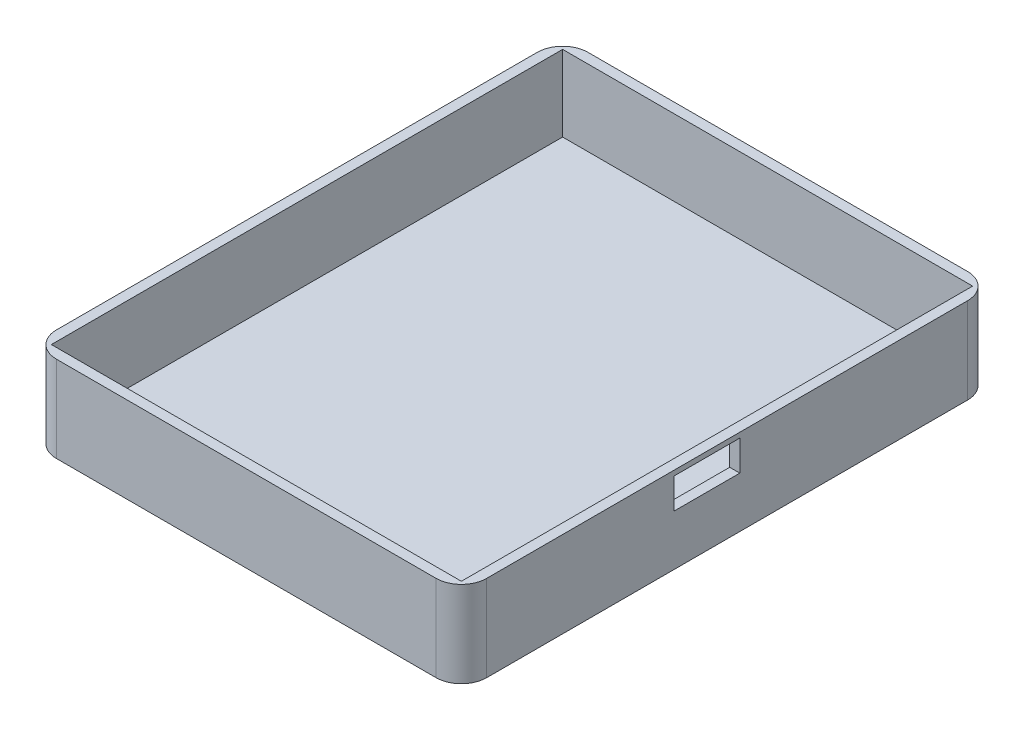
from build123d import *

# Parameters (mm, degrees)
SKETCH1_W           = 85
SKETCH1_H           = 105
BOSS_EXTRUDE1_DEPTH = 17
SHELL1_T            = -2
SKETCH3_W           = 13
SKETCH3_H           = 6
CUT_EXTRUDE1_DEPTH  = 10
FILLET1_R           = 5


with BuildPart() as part:
    # Sketch1 → Boss-Extrude1 (new body)
    with BuildSketch(Plane(origin=(0, 0, 0), x_dir=(1, 0, 0), z_dir=(0, 1, 0))):
        Rectangle(SKETCH1_W, SKETCH1_H)
    extrude(amount=BOSS_EXTRUDE1_DEPTH)

    # Shell1
    shell1_openings = [part.faces().sort_by_distance(p)[0] for p in [
        (0, 17, 0),
    ]]
    offset(amount=SHELL1_T, openings=shell1_openings, kind=Kind.INTERSECTION)

    # Sketch3 → Cut-Extrude1 (cut)
    with BuildSketch(Plane(origin=(42.5, 0, 0), x_dir=(0, 0, -1), z_dir=(1, 0, 0))):
        with Locations((-4, 13)):
            Rectangle(SKETCH3_W, SKETCH3_H)
    extrude(amount=-CUT_EXTRUDE1_DEPTH, mode=Mode.SUBTRACT)

    # Fillet1
    fillet1_edges = [part.edges().sort_by_distance(p)[0] for p in [
        (42.5, 8.5, 52.5),
        (-42.5, 8.5, 52.5),
        (-42.5, 8.5, -52.5),
        (42.5, 8.5, -52.5),
    ]]
    fillet(fillet1_edges, radius=FILLET1_R)


solid = part.part
